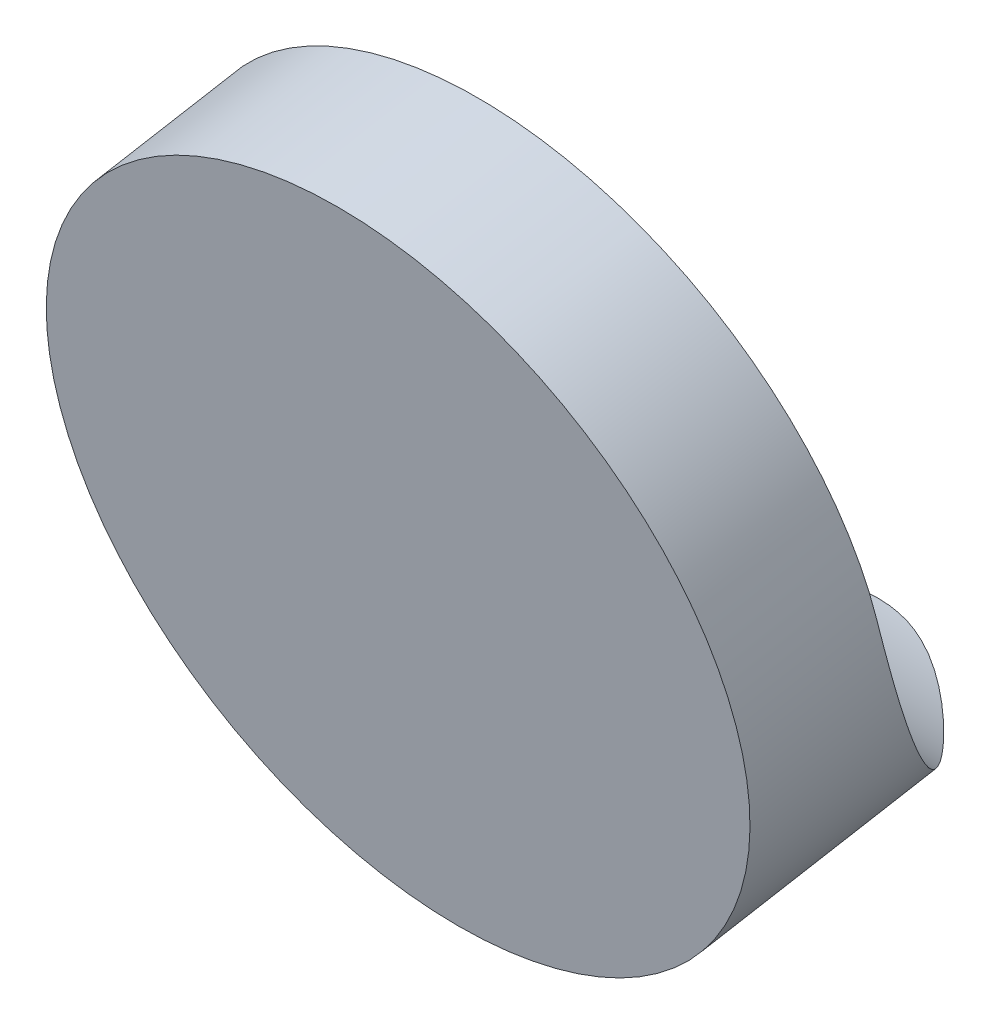
from build123d import *

# Parameters (mm, degrees)
SKETCH2_R           = 12.2
BOSS_EXTRUDE1_DEPTH = 15
BOSS_EXTRUDE2_DEPTH = 25


with BuildPart() as part:
    # Sketch2 → Boss-Extrude1 (new body)
    with BuildSketch(Plane(origin=(0, 2.526178565, -14.326670571), x_dir=(0, -0.984807753, -0.173648178), z_dir=(0, -0.173648178, 0.984807753))):
        with Locations((-84.490615604, 0)):
            Circle(SKETCH2_R)
    extrude(amount=-BOSS_EXTRUDE1_DEPTH)


with BuildPart() as body_2:
    # Sketch1 → Boss-Extrude2 (new body, symmetric)
    with BuildSketch(Plane(origin=(0, 0, 0), x_dir=(0, 0, -1), z_dir=(1, 0, 0))):
        with BuildLine():
            Line((4.367840897, 87.799360654), (2.460560139, 98.616087344))
            Line((2.460560139, 98.616087344), (1.59231925, 103.540126109))
            Line((1.59231925, 103.540126109), (11.44039678, 105.276607886))
            Line((11.44039678, 105.276607886), (16.545653204, 76.323259947))
            ThreePointArc((16.545653204, 76.323259947), (8.553554718, 80.041746373), (4.367840897, 87.799360654))
        make_face()
    extrude(amount=BOSS_EXTRUDE2_DEPTH, both=True)


with BuildPart() as part_1:
    add(part.part)

    # Combine1: cut body 2
    add(body_2.part, mode=Mode.SUBTRACT)


solid = part_1.part
